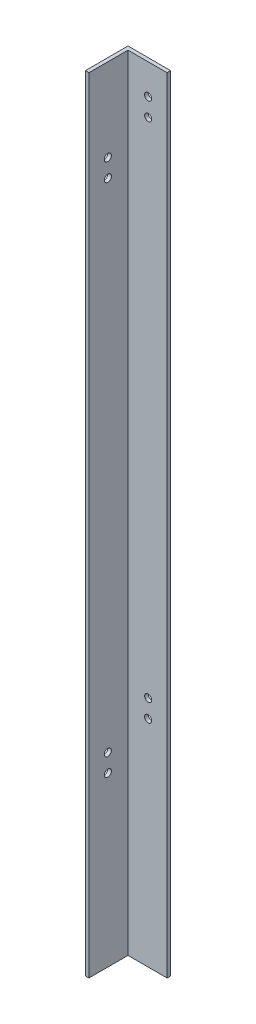
from build123d import *

# Parameters (mm, degrees)
CROQUIS1_W              = 38.1
CROQUIS1_H              = 700
SALIENTE_EXTRUIR1_DEPTH = 3.2
CROQUIS2_W              = 3.2
CROQUIS2_H              = 700
SALIENTE_EXTRUIR2_DEPTH = 34.9
CROQUIS5_R              = 3.175
CORTAR_EXTRUIR1_DEPTH   = 10
CROQUIS6_R              = 3.175
CORTAR_EXTRUIR2_DEPTH   = 10


with BuildPart() as part:
    # Croquis1 → Saliente-Extruir1 (new body)
    with BuildSketch(Plane.XY):
        with Locations((-19.05, 350)):
            Rectangle(CROQUIS1_W, CROQUIS1_H)
    extrude(amount=SALIENTE_EXTRUIR1_DEPTH)

    # Croquis2 → Saliente-Extruir2 (add)
    with BuildSketch(Plane.XY.offset(3.2)):
        with Locations((-36.5, 350)):
            Rectangle(CROQUIS2_W, CROQUIS2_H)
    extrude(amount=SALIENTE_EXTRUIR2_DEPTH)

    # Croquis5 → Cortar-Extruir1 (cut)
    with BuildSketch(Plane.XY.offset(3.2)):
        with Locations((-16.9, 673)):
            Circle(CROQUIS5_R)
        with Locations((-16.9, 657)):
            Circle(CROQUIS5_R)
        with Locations((-16.9, 208)):
            Circle(CROQUIS5_R)
        with Locations((-16.9, 192)):
            Circle(CROQUIS5_R)
    extrude(amount=-CORTAR_EXTRUIR1_DEPTH, mode=Mode.SUBTRACT)

    # Croquis6 → Cortar-Extruir2 (cut)
    with BuildSketch(Plane(origin=(-34.9, 0, 0), x_dir=(0, 0, -1), z_dir=(1, 0, 0))):
        with Locations((-21.2, 626)):
            Circle(CROQUIS6_R)
        with Locations((-21.2, 610)):
            Circle(CROQUIS6_R)
        with Locations((-21.2, 166)):
            Circle(CROQUIS6_R)
        with Locations((-21.2, 150)):
            Circle(CROQUIS6_R)
    extrude(amount=-CORTAR_EXTRUIR2_DEPTH, mode=Mode.SUBTRACT)


solid = part.part
